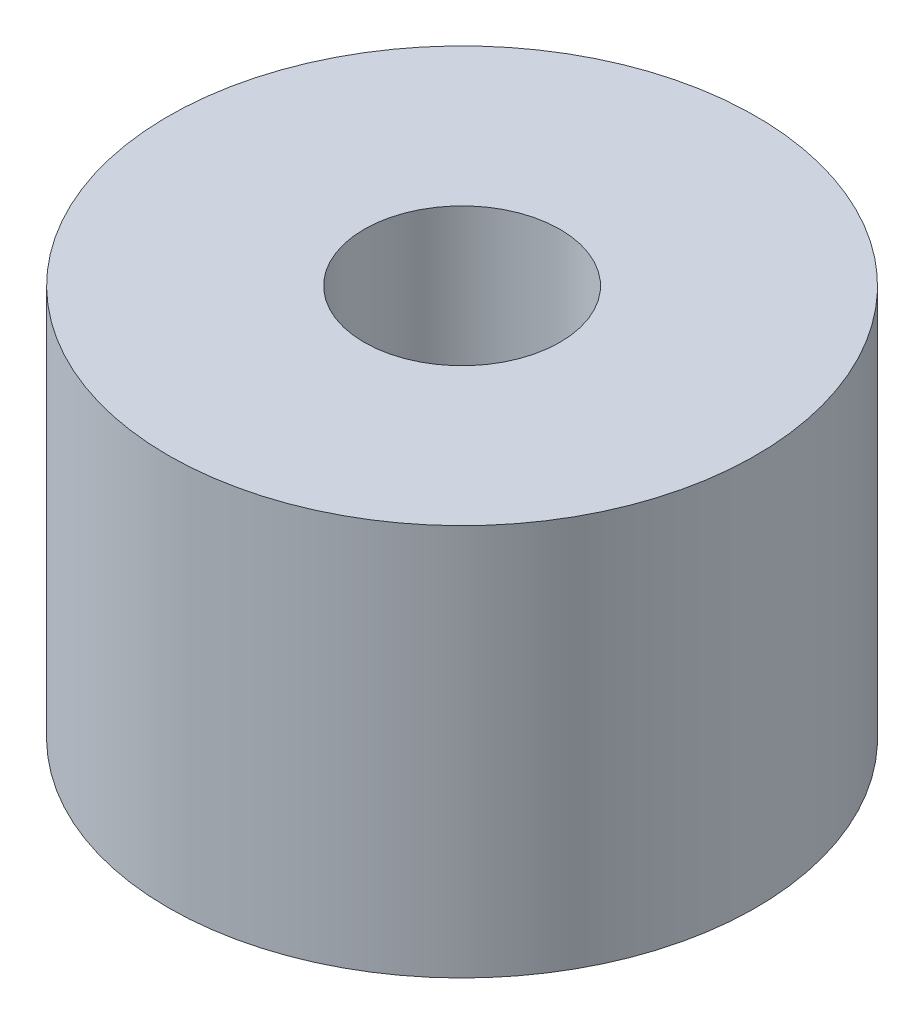
from build123d import *

# Parameters (mm, degrees)
ESQUISSE1_R      = 15
ESQUISSE1_R_2    = 5
EXTRUSION1_DEPTH = 20


with BuildPart() as part:
    # Esquisse1 → Extrusion1 (new body)
    with BuildSketch(Plane(origin=(0, 0, 0), x_dir=(1, 0, 0), z_dir=(0, 1, 0))):
        Circle(ESQUISSE1_R)
        Circle(ESQUISSE1_R_2, mode=Mode.SUBTRACT)
    extrude(amount=EXTRUSION1_DEPTH)


solid = part.part
